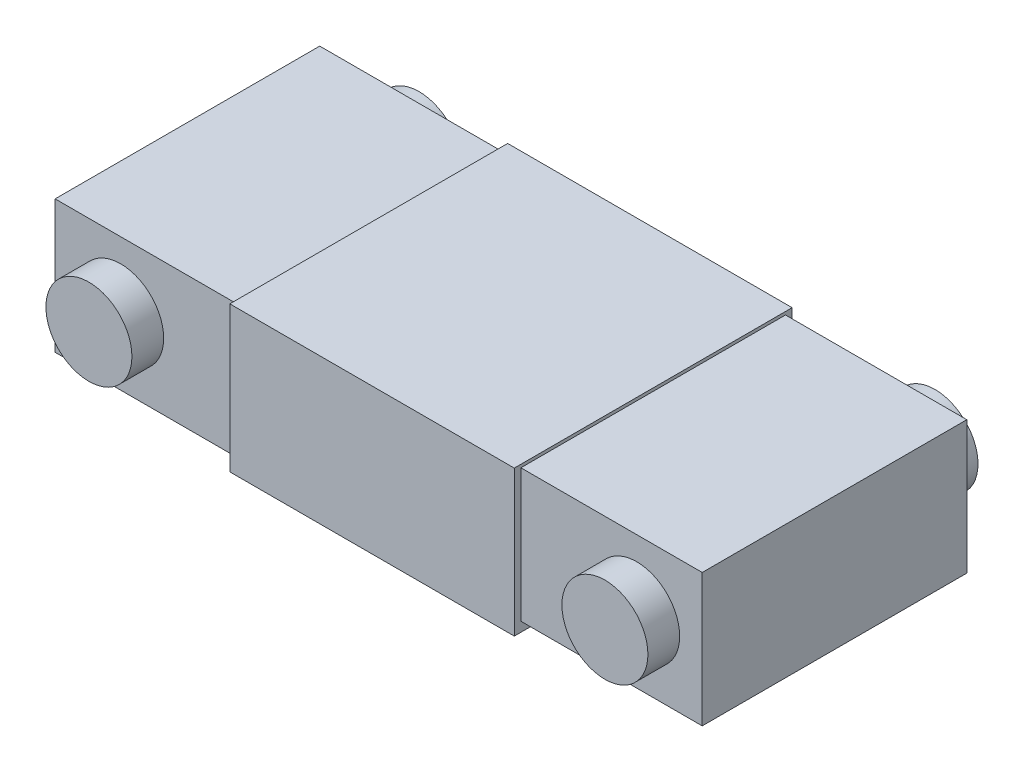
from build123d import *

# Parameters (mm, degrees)
EXTRUDE_1_DEPTH      = 20
SKETCH_2_W           = 43
SKETCH_2_H           = 22
EXTRUDE_2_DEPTH      = 21
SKETCH_3_R           = 6.5
EXTRUDE_4_DEPTH      = 24.8
EXTRUDE_4_DEPTH_BACK = 25.1


with BuildPart() as part:
    # Эскиз1 → Бобышка-Вытянуть1 (new body, symmetric)
    with BuildSketch(Plane.XY):
        Polygon((17.5, -10.045), (17.5, -11.495), (60.5, -11.495), (60.5, -10.045), (87.91, -10.045), (87.91, 10.045), (60.5, 10.045), (60.5, 10.505), (17.5, 10.505), (17.5, 10.045), (-9.91, 10.045), (-9.91, -10.045), align=None)
    extrude(amount=EXTRUDE_1_DEPTH, both=True)

    # Эскиз2 → Бобышка-Вытянуть2 (add, symmetric)
    with BuildSketch(Plane.XY):
        with Locations((39, -0.495)):
            Rectangle(SKETCH_2_W, SKETCH_2_H)
    extrude(amount=EXTRUDE_2_DEPTH, both=True)

    # Эскиз3 → Бобышка-Вытянуть4 (add, two sides)
    with BuildSketch(Plane.XY) as extrude_4_sk:
        Circle(SKETCH_3_R)
        with Locations((78, 0)):
            Circle(SKETCH_3_R)
    extrude(amount=EXTRUDE_4_DEPTH)
    extrude(extrude_4_sk.sketch, amount=-EXTRUDE_4_DEPTH_BACK)


solid = part.part
